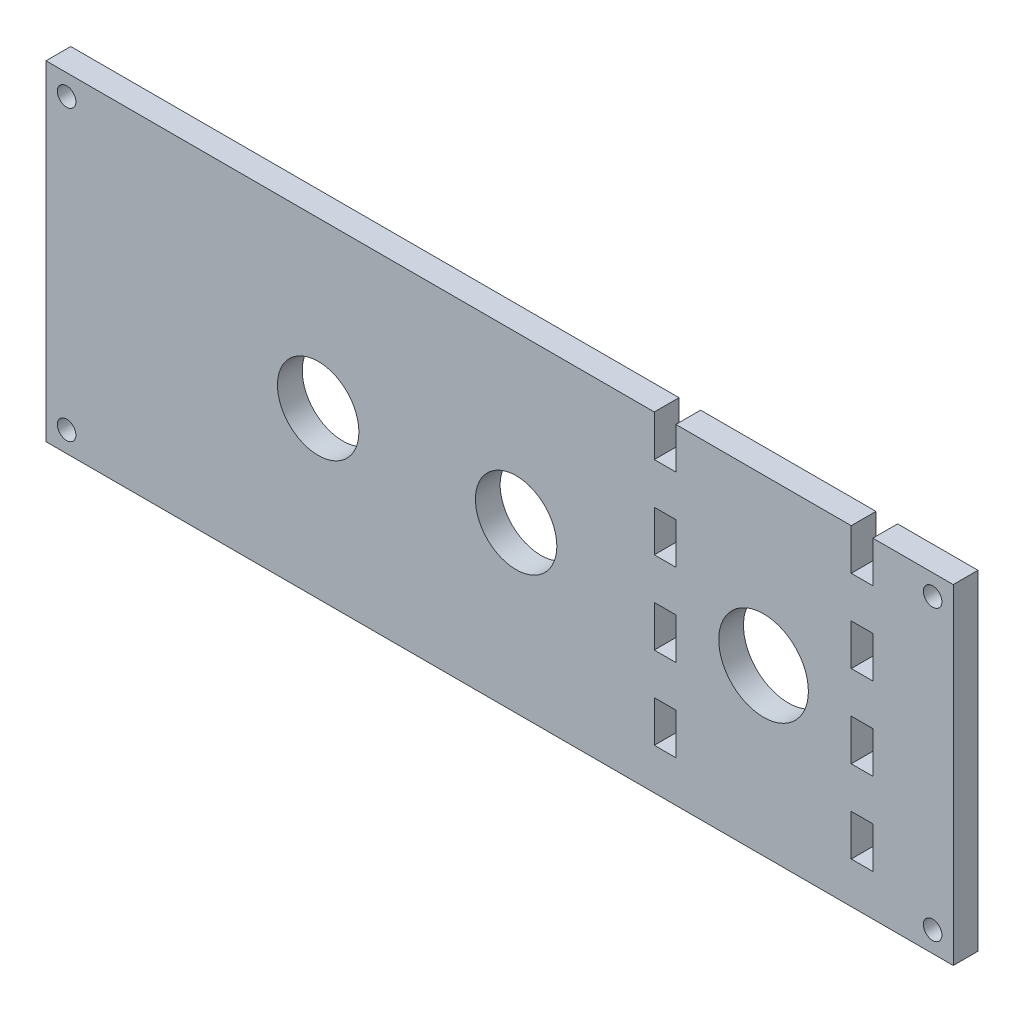
from build123d import *

# Parameters (mm, degrees)
SKETCH1_W           = 110
SKETCH1_H           = 40
BOSS_EXTRUDE1_DEPTH = 3
SKETCH2_W           = 2.62
SKETCH2_H           = 5
SKETCH2_R           = 4.9365
SKETCH2_R_2         = 1.125
SKETCH2_R_3         = 5.435
CUT_EXTRUDE1_DEPTH  = 4


with BuildPart() as part:
    # Sketch1 → Boss-Extrude1 (new body)
    with BuildSketch(Plane.XY):
        with Locations((55, 20)):
            Rectangle(SKETCH1_W, SKETCH1_H)
    extrude(amount=BOSS_EXTRUDE1_DEPTH)

    # Sketch2 → Cut-Extrude1 (cut, through all)
    with BuildSketch(Plane.XY.offset(3)):
        with Locations((98.94, 37.5)):
            Rectangle(SKETCH2_W, SKETCH2_H)
        with Locations((75.06, 37.5)):
            Rectangle(SKETCH2_W, SKETCH2_H)
        with Locations((75.06, 27.5)):
            Rectangle(SKETCH2_W, SKETCH2_H)
        with Locations((75.06, 17.5)):
            Rectangle(SKETCH2_W, SKETCH2_H)
        with Locations((75.06, 7.5)):
            Rectangle(SKETCH2_W, SKETCH2_H)
        with Locations((98.94, 27.5)):
            Rectangle(SKETCH2_W, SKETCH2_H)
        with Locations((98.94, 17.5)):
            Rectangle(SKETCH2_W, SKETCH2_H)
        with Locations((98.94, 7.5)):
            Rectangle(SKETCH2_W, SKETCH2_H)
        with Locations((33, 20)):
            Circle(SKETCH2_R)
        with Locations((57, 20)):
            Circle(SKETCH2_R)
        with Locations((2.5, 37.5)):
            Circle(SKETCH2_R_2)
        with Locations((107.5, 37.5)):
            Circle(SKETCH2_R_2)
        with Locations((107.5, 2.5)):
            Circle(SKETCH2_R_2)
        with Locations((2.5, 2.5)):
            Circle(SKETCH2_R_2)
        with Locations((87, 20)):
            Circle(SKETCH2_R_3)
    extrude(amount=-CUT_EXTRUDE1_DEPTH, mode=Mode.SUBTRACT)


solid = part.part
